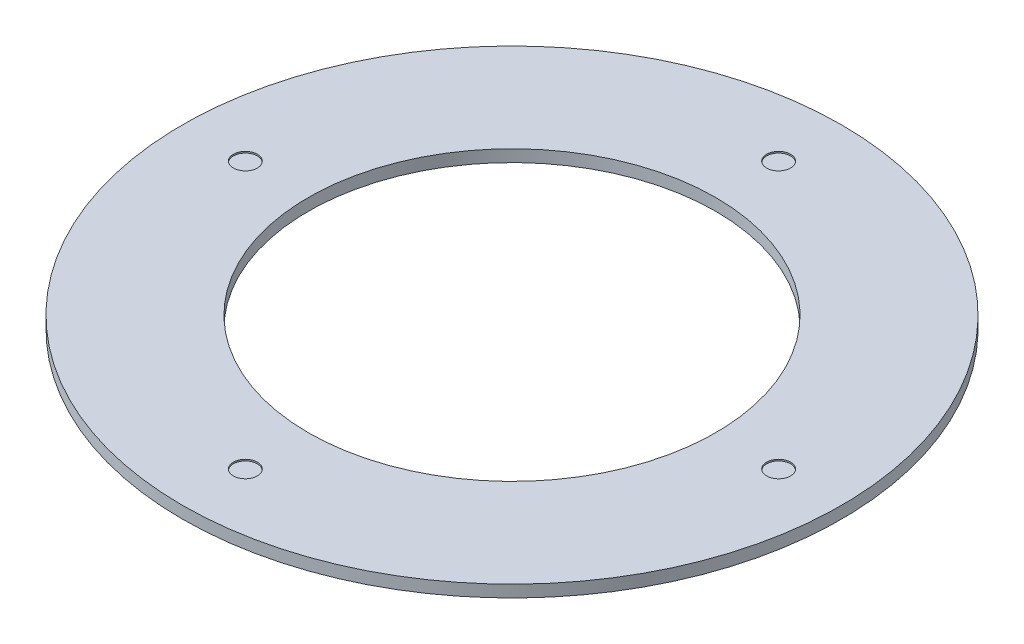
from build123d import *

# Parameters (mm, degrees)
SKETCH1_R           = 55
BOSS_EXTRUDE1_DEPTH = 2
SKETCH2_R           = 2
CUT_EXTRUDE1_DEPTH  = 0.25
SKETCH3_R           = 34
CUT_EXTRUDE2_DEPTH  = 10


with BuildPart() as part:
    # Sketch1 → Boss-Extrude1 (new body)
    with BuildSketch(Plane(origin=(0, 0, 0), x_dir=(1, 0, 0), z_dir=(0, 1, 0))):
        Circle(SKETCH1_R)
    extrude(amount=BOSS_EXTRUDE1_DEPTH)

    # Sketch2 → Cut-Extrude1 (cut)
    with BuildSketch(Plane(origin=(0, 2, 0), x_dir=(1, 0, 0), z_dir=(0, 1, 0))):
        with Locations((0, 44.5)):
            Circle(SKETCH2_R)
        with Locations((44.5, 0)):
            Circle(SKETCH2_R)
        with Locations((0, -44.5)):
            Circle(SKETCH2_R)
        with Locations((-44.5, 0)):
            Circle(SKETCH2_R)
    extrude(amount=-CUT_EXTRUDE1_DEPTH, mode=Mode.SUBTRACT)

    # Sketch3 → Cut-Extrude2 (cut)
    with BuildSketch(Plane(origin=(0, 2, 0), x_dir=(1, 0, 0), z_dir=(0, 1, 0))):
        Circle(SKETCH3_R)
    extrude(amount=-CUT_EXTRUDE2_DEPTH, mode=Mode.SUBTRACT)


solid = part.part
